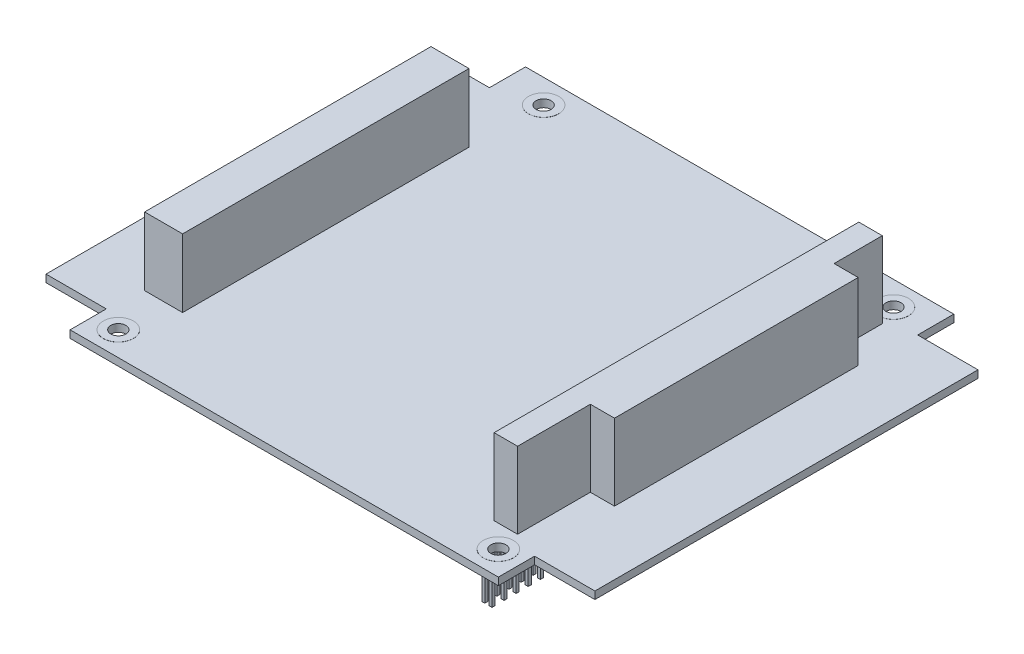
from build123d import *

# Parameters (mm, degrees)
BASE_EXTRUDE_DEPTH         = 1.57
SKETCH2_R                  = 1.59
MOUNTING_HOLES_DEPTH       = 76.101891787
TOP_START                  = 0.02
SKETCH3_R                  = 3.175
SKETCH3_R_2                = 1.59
TOP_PADS_DEPTH             = 0.02
SKETCH4_R                  = 3.175
SKETCH4_R_2                = 1.59
BOTT_PADS_DEPTH            = 0.02
ISA_CNCT_DEPTH             = 16.05
SKETCH6_W                  = 8
SKETCH6_H                  = 60.3
PCI_CNCT_DEPTH             = 14.35
SKETCH7_W                  = 11.3
SKETCH7_H                  = 63.35
SKETCH7_W_2                = 8.51
SKETCH7_H_2                = 60.96
PCI_CNCT_SHROUD_DEPTH      = 11.18
SKETCH8_W                  = 0.64
SKETCH8_H                  = 0.64
BOT_ISA_DEPTH              = 10.67
LPATTERN1_COUNT            = 32
LPATTERN1_PITCH            = 2.54
SKETCH9_W                  = 0.64
SKETCH9_H                  = 0.64
BOSS_EXTRUDE7_DEPTH        = 10.67
LPATTERN2_COUNT            = 20
LPATTERN2_PITCH            = 2.54
SKETCH10_W                 = 0.5
SKETCH10_H                 = 0.5
PCI_BASE_DEPTH             = 10.41
LPATTERN3_COUNT            = 30
LPATTERN3_PITCH            = 2
LPATTERN4_COUNT            = 4
LPATTERN4_PITCH            = 2
LPATTERN4_COPY_1_SKETCH_W  = 0.5
LPATTERN4_COPY_1_SKETCH_H  = 0.5
LPATTERN4_COPY_1_DEPTH     = 10.41
LPATTERN4_COPY_2_SKETCH_W  = 0.5
LPATTERN4_COPY_2_SKETCH_H  = 0.5
LPATTERN4_COPY_2_DEPTH     = 10.41
LPATTERN4_COPY_3_SKETCH_W  = 0.5
LPATTERN4_COPY_3_SKETCH_H  = 0.5
LPATTERN4_COPY_3_DEPTH     = 10.41
LPATTERN4_COPY_4_SKETCH_W  = 0.5
LPATTERN4_COPY_4_SKETCH_H  = 0.5
LPATTERN4_COPY_4_DEPTH     = 10.41
LPATTERN4_COPY_5_SKETCH_W  = 0.5
LPATTERN4_COPY_5_SKETCH_H  = 0.5
LPATTERN4_COPY_5_DEPTH     = 10.41
LPATTERN4_COPY_6_SKETCH_W  = 0.5
LPATTERN4_COPY_6_SKETCH_H  = 0.5
LPATTERN4_COPY_6_DEPTH     = 10.41
LPATTERN4_COPY_7_SKETCH_W  = 0.5
LPATTERN4_COPY_7_SKETCH_H  = 0.5
LPATTERN4_COPY_7_DEPTH     = 10.41
LPATTERN4_COPY_8_SKETCH_W  = 0.5
LPATTERN4_COPY_8_SKETCH_H  = 0.5
LPATTERN4_COPY_8_DEPTH     = 10.41
LPATTERN4_COPY_9_SKETCH_W  = 0.5
LPATTERN4_COPY_9_SKETCH_H  = 0.5
LPATTERN4_COPY_9_DEPTH     = 10.41
LPATTERN4_COPY_10_SKETCH_W = 0.5
LPATTERN4_COPY_10_SKETCH_H = 0.5
LPATTERN4_COPY_10_DEPTH    = 10.41
LPATTERN4_COPY_11_SKETCH_W = 0.5
LPATTERN4_COPY_11_SKETCH_H = 0.5
LPATTERN4_COPY_11_DEPTH    = 10.41
LPATTERN4_COPY_12_SKETCH_W = 0.5
LPATTERN4_COPY_12_SKETCH_H = 0.5
LPATTERN4_COPY_12_DEPTH    = 10.41
LPATTERN4_COPY_13_SKETCH_W = 0.5
LPATTERN4_COPY_13_SKETCH_H = 0.5
LPATTERN4_COPY_13_DEPTH    = 10.41
LPATTERN4_COPY_14_SKETCH_W = 0.5
LPATTERN4_COPY_14_SKETCH_H = 0.5
LPATTERN4_COPY_14_DEPTH    = 10.41
LPATTERN4_COPY_15_SKETCH_W = 0.5
LPATTERN4_COPY_15_SKETCH_H = 0.5
LPATTERN4_COPY_15_DEPTH    = 10.41
LPATTERN4_COPY_16_SKETCH_W = 0.5
LPATTERN4_COPY_16_SKETCH_H = 0.5
LPATTERN4_COPY_16_DEPTH    = 10.41
LPATTERN4_COPY_17_SKETCH_W = 0.5
LPATTERN4_COPY_17_SKETCH_H = 0.5
LPATTERN4_COPY_17_DEPTH    = 10.41
LPATTERN4_COPY_18_SKETCH_W = 0.5
LPATTERN4_COPY_18_SKETCH_H = 0.5
LPATTERN4_COPY_18_DEPTH    = 10.41
LPATTERN4_COPY_19_SKETCH_W = 0.5
LPATTERN4_COPY_19_SKETCH_H = 0.5
LPATTERN4_COPY_19_DEPTH    = 10.41
LPATTERN4_COPY_20_SKETCH_W = 0.5
LPATTERN4_COPY_20_SKETCH_H = 0.5
LPATTERN4_COPY_20_DEPTH    = 10.41
LPATTERN4_COPY_21_SKETCH_W = 0.5
LPATTERN4_COPY_21_SKETCH_H = 0.5
LPATTERN4_COPY_21_DEPTH    = 10.41
LPATTERN4_COPY_22_SKETCH_W = 0.5
LPATTERN4_COPY_22_SKETCH_H = 0.5
LPATTERN4_COPY_22_DEPTH    = 10.41
LPATTERN4_COPY_23_SKETCH_W = 0.5
LPATTERN4_COPY_23_SKETCH_H = 0.5
LPATTERN4_COPY_23_DEPTH    = 10.41
LPATTERN4_COPY_24_SKETCH_W = 0.5
LPATTERN4_COPY_24_SKETCH_H = 0.5
LPATTERN4_COPY_24_DEPTH    = 10.41
LPATTERN4_COPY_25_SKETCH_W = 0.5
LPATTERN4_COPY_25_SKETCH_H = 0.5
LPATTERN4_COPY_25_DEPTH    = 10.41
LPATTERN4_COPY_26_SKETCH_W = 0.5
LPATTERN4_COPY_26_SKETCH_H = 0.5
LPATTERN4_COPY_26_DEPTH    = 10.41
LPATTERN4_COPY_27_SKETCH_W = 0.5
LPATTERN4_COPY_27_SKETCH_H = 0.5
LPATTERN4_COPY_27_DEPTH    = 10.41
LPATTERN4_COPY_28_SKETCH_W = 0.5
LPATTERN4_COPY_28_SKETCH_H = 0.5
LPATTERN4_COPY_28_DEPTH    = 10.41
LPATTERN4_COPY_29_SKETCH_W = 0.5
LPATTERN4_COPY_29_SKETCH_H = 0.5
LPATTERN4_COPY_29_DEPTH    = 10.41
LPATTERN4_COPY_30_SKETCH_W = 0.5
LPATTERN4_COPY_30_SKETCH_H = 0.5
LPATTERN4_COPY_30_DEPTH    = 10.41
LPATTERN4_COPY_31_SKETCH_W = 0.5
LPATTERN4_COPY_31_SKETCH_H = 0.5
LPATTERN4_COPY_31_DEPTH    = 10.41
LPATTERN4_COPY_32_SKETCH_W = 0.5
LPATTERN4_COPY_32_SKETCH_H = 0.5
LPATTERN4_COPY_32_DEPTH    = 10.41
LPATTERN4_COPY_33_SKETCH_W = 0.5
LPATTERN4_COPY_33_SKETCH_H = 0.5
LPATTERN4_COPY_33_DEPTH    = 10.41
LPATTERN4_COPY_34_SKETCH_W = 0.5
LPATTERN4_COPY_34_SKETCH_H = 0.5
LPATTERN4_COPY_34_DEPTH    = 10.41
LPATTERN4_COPY_35_SKETCH_W = 0.5
LPATTERN4_COPY_35_SKETCH_H = 0.5
LPATTERN4_COPY_35_DEPTH    = 10.41
LPATTERN4_COPY_36_SKETCH_W = 0.5
LPATTERN4_COPY_36_SKETCH_H = 0.5
LPATTERN4_COPY_36_DEPTH    = 10.41
LPATTERN4_COPY_37_SKETCH_W = 0.5
LPATTERN4_COPY_37_SKETCH_H = 0.5
LPATTERN4_COPY_37_DEPTH    = 10.41
LPATTERN4_COPY_38_SKETCH_W = 0.5
LPATTERN4_COPY_38_SKETCH_H = 0.5
LPATTERN4_COPY_38_DEPTH    = 10.41
LPATTERN4_COPY_39_SKETCH_W = 0.5
LPATTERN4_COPY_39_SKETCH_H = 0.5
LPATTERN4_COPY_39_DEPTH    = 10.41
LPATTERN4_COPY_40_SKETCH_W = 0.5
LPATTERN4_COPY_40_SKETCH_H = 0.5
LPATTERN4_COPY_40_DEPTH    = 10.41
LPATTERN4_COPY_41_SKETCH_W = 0.5
LPATTERN4_COPY_41_SKETCH_H = 0.5
LPATTERN4_COPY_41_DEPTH    = 10.41
LPATTERN4_COPY_42_SKETCH_W = 0.5
LPATTERN4_COPY_42_SKETCH_H = 0.5
LPATTERN4_COPY_42_DEPTH    = 10.41
LPATTERN4_COPY_43_SKETCH_W = 0.5
LPATTERN4_COPY_43_SKETCH_H = 0.5
LPATTERN4_COPY_43_DEPTH    = 10.41
LPATTERN4_COPY_44_SKETCH_W = 0.5
LPATTERN4_COPY_44_SKETCH_H = 0.5
LPATTERN4_COPY_44_DEPTH    = 10.41
LPATTERN4_COPY_45_SKETCH_W = 0.5
LPATTERN4_COPY_45_SKETCH_H = 0.5
LPATTERN4_COPY_45_DEPTH    = 10.41
LPATTERN4_COPY_46_SKETCH_W = 0.5
LPATTERN4_COPY_46_SKETCH_H = 0.5
LPATTERN4_COPY_46_DEPTH    = 10.41
LPATTERN4_COPY_47_SKETCH_W = 0.5
LPATTERN4_COPY_47_SKETCH_H = 0.5
LPATTERN4_COPY_47_DEPTH    = 10.41
LPATTERN4_COPY_48_SKETCH_W = 0.5
LPATTERN4_COPY_48_SKETCH_H = 0.5
LPATTERN4_COPY_48_DEPTH    = 10.41
LPATTERN4_COPY_49_SKETCH_W = 0.5
LPATTERN4_COPY_49_SKETCH_H = 0.5
LPATTERN4_COPY_49_DEPTH    = 10.41
LPATTERN4_COPY_50_SKETCH_W = 0.5
LPATTERN4_COPY_50_SKETCH_H = 0.5
LPATTERN4_COPY_50_DEPTH    = 10.41
LPATTERN4_COPY_51_SKETCH_W = 0.5
LPATTERN4_COPY_51_SKETCH_H = 0.5
LPATTERN4_COPY_51_DEPTH    = 10.41
LPATTERN4_COPY_52_SKETCH_W = 0.5
LPATTERN4_COPY_52_SKETCH_H = 0.5
LPATTERN4_COPY_52_DEPTH    = 10.41
LPATTERN4_COPY_53_SKETCH_W = 0.5
LPATTERN4_COPY_53_SKETCH_H = 0.5
LPATTERN4_COPY_53_DEPTH    = 10.41
LPATTERN4_COPY_54_SKETCH_W = 0.5
LPATTERN4_COPY_54_SKETCH_H = 0.5
LPATTERN4_COPY_54_DEPTH    = 10.41
LPATTERN4_COPY_55_SKETCH_W = 0.5
LPATTERN4_COPY_55_SKETCH_H = 0.5
LPATTERN4_COPY_55_DEPTH    = 10.41
LPATTERN4_COPY_56_SKETCH_W = 0.5
LPATTERN4_COPY_56_SKETCH_H = 0.5
LPATTERN4_COPY_56_DEPTH    = 10.41
LPATTERN4_COPY_57_SKETCH_W = 0.5
LPATTERN4_COPY_57_SKETCH_H = 0.5
LPATTERN4_COPY_57_DEPTH    = 10.41
LPATTERN4_COPY_58_SKETCH_W = 0.5
LPATTERN4_COPY_58_SKETCH_H = 0.5
LPATTERN4_COPY_58_DEPTH    = 10.41
LPATTERN4_COPY_59_SKETCH_W = 0.5
LPATTERN4_COPY_59_SKETCH_H = 0.5
LPATTERN4_COPY_59_DEPTH    = 10.41
LPATTERN4_COPY_60_SKETCH_W = 0.5
LPATTERN4_COPY_60_SKETCH_H = 0.5
LPATTERN4_COPY_60_DEPTH    = 10.41
LPATTERN4_COPY_61_SKETCH_W = 0.5
LPATTERN4_COPY_61_SKETCH_H = 0.5
LPATTERN4_COPY_61_DEPTH    = 10.41
LPATTERN4_COPY_62_SKETCH_W = 0.5
LPATTERN4_COPY_62_SKETCH_H = 0.5
LPATTERN4_COPY_62_DEPTH    = 10.41
LPATTERN4_COPY_63_SKETCH_W = 0.5
LPATTERN4_COPY_63_SKETCH_H = 0.5
LPATTERN4_COPY_63_DEPTH    = 10.41
LPATTERN4_COPY_64_SKETCH_W = 0.5
LPATTERN4_COPY_64_SKETCH_H = 0.5
LPATTERN4_COPY_64_DEPTH    = 10.41
LPATTERN4_COPY_65_SKETCH_W = 0.5
LPATTERN4_COPY_65_SKETCH_H = 0.5
LPATTERN4_COPY_65_DEPTH    = 10.41
LPATTERN4_COPY_66_SKETCH_W = 0.5
LPATTERN4_COPY_66_SKETCH_H = 0.5
LPATTERN4_COPY_66_DEPTH    = 10.41
LPATTERN4_COPY_67_SKETCH_W = 0.5
LPATTERN4_COPY_67_SKETCH_H = 0.5
LPATTERN4_COPY_67_DEPTH    = 10.41
LPATTERN4_COPY_68_SKETCH_W = 0.5
LPATTERN4_COPY_68_SKETCH_H = 0.5
LPATTERN4_COPY_68_DEPTH    = 10.41
LPATTERN4_COPY_69_SKETCH_W = 0.5
LPATTERN4_COPY_69_SKETCH_H = 0.5
LPATTERN4_COPY_69_DEPTH    = 10.41
LPATTERN4_COPY_70_SKETCH_W = 0.5
LPATTERN4_COPY_70_SKETCH_H = 0.5
LPATTERN4_COPY_70_DEPTH    = 10.41
LPATTERN4_COPY_71_SKETCH_W = 0.5
LPATTERN4_COPY_71_SKETCH_H = 0.5
LPATTERN4_COPY_71_DEPTH    = 10.41
LPATTERN4_COPY_72_SKETCH_W = 0.5
LPATTERN4_COPY_72_SKETCH_H = 0.5
LPATTERN4_COPY_72_DEPTH    = 10.41
LPATTERN4_COPY_73_SKETCH_W = 0.5
LPATTERN4_COPY_73_SKETCH_H = 0.5
LPATTERN4_COPY_73_DEPTH    = 10.41
LPATTERN4_COPY_74_SKETCH_W = 0.5
LPATTERN4_COPY_74_SKETCH_H = 0.5
LPATTERN4_COPY_74_DEPTH    = 10.41
LPATTERN4_COPY_75_SKETCH_W = 0.5
LPATTERN4_COPY_75_SKETCH_H = 0.5
LPATTERN4_COPY_75_DEPTH    = 10.41
LPATTERN4_COPY_76_SKETCH_W = 0.5
LPATTERN4_COPY_76_SKETCH_H = 0.5
LPATTERN4_COPY_76_DEPTH    = 10.41
LPATTERN4_COPY_77_SKETCH_W = 0.5
LPATTERN4_COPY_77_SKETCH_H = 0.5
LPATTERN4_COPY_77_DEPTH    = 10.41
LPATTERN4_COPY_78_SKETCH_W = 0.5
LPATTERN4_COPY_78_SKETCH_H = 0.5
LPATTERN4_COPY_78_DEPTH    = 10.41
LPATTERN4_COPY_79_SKETCH_W = 0.5
LPATTERN4_COPY_79_SKETCH_H = 0.5
LPATTERN4_COPY_79_DEPTH    = 10.41
LPATTERN4_COPY_80_SKETCH_W = 0.5
LPATTERN4_COPY_80_SKETCH_H = 0.5
LPATTERN4_COPY_80_DEPTH    = 10.41
LPATTERN4_COPY_81_SKETCH_W = 0.5
LPATTERN4_COPY_81_SKETCH_H = 0.5
LPATTERN4_COPY_81_DEPTH    = 10.41
LPATTERN4_COPY_82_SKETCH_W = 0.5
LPATTERN4_COPY_82_SKETCH_H = 0.5
LPATTERN4_COPY_82_DEPTH    = 10.41
LPATTERN4_COPY_83_SKETCH_W = 0.5
LPATTERN4_COPY_83_SKETCH_H = 0.5
LPATTERN4_COPY_83_DEPTH    = 10.41
LPATTERN4_COPY_84_SKETCH_W = 0.5
LPATTERN4_COPY_84_SKETCH_H = 0.5
LPATTERN4_COPY_84_DEPTH    = 10.41
LPATTERN4_COPY_85_SKETCH_W = 0.5
LPATTERN4_COPY_85_SKETCH_H = 0.5
LPATTERN4_COPY_85_DEPTH    = 10.41
LPATTERN4_COPY_86_SKETCH_W = 0.5
LPATTERN4_COPY_86_SKETCH_H = 0.5
LPATTERN4_COPY_86_DEPTH    = 10.41
LPATTERN4_COPY_87_SKETCH_W = 0.5
LPATTERN4_COPY_87_SKETCH_H = 0.5
LPATTERN4_COPY_87_DEPTH    = 10.41


with BuildPart() as part:
    # Sketch1 → Base-Extrude (new body)
    with BuildSketch(Plane(origin=(0, 0, 0), x_dir=(1, 0, 0), z_dir=(0, 1, 0))):
        Polygon((-45.085, 47.945), (45.085, 47.945), (45.085, 40.343374485), (57.785, 40.343374485), (57.785, -40.318146652), (45.085, -40.318146652), (45.085, -47.945), (-45.085, -47.945), (-45.085, -40.318146652), (-57.785, -40.318146652), (-57.785, 40.343374485), (-45.085, 40.343374485), align=None)
    extrude(amount=BASE_EXTRUDE_DEPTH)

    # Sketch2 → Mounting Holes (cut, through all)
    with BuildSketch(Plane(origin=(0, 1.57, 0), x_dir=(-1, 0, 0), z_dir=(0, 1, 0))):
        with Locations(Location((36.195, -42.865, 0), (0, 0, 90))):
            Circle(SKETCH2_R)
        with Locations(Location((40.005, 42.865, 0), (0, 0, 90))):
            Circle(SKETCH2_R)
        with Locations(Location((-40.005, 42.865, 0), (0, 0, 90))):
            Circle(SKETCH2_R)
        with Locations(Location((-37.465, -42.865, 0), (0, 0, 90))):
            Circle(SKETCH2_R)
    extrude(amount=-MOUNTING_HOLES_DEPTH, mode=Mode.SUBTRACT)

    # Sketch3 → Top Pads (add)
    # profile 1 of 4: a face of its own
    with BuildSketch(Plane(origin=(0, 1.57, 0), x_dir=(-1, 0, 0), z_dir=(0, 1, 0)).offset(TOP_START)):
        with Locations(Location((36.195, -42.865, 0), (0, 0, 270))):
            Circle(SKETCH3_R)
        with Locations(Location((36.195, -42.865, 0), (0, 0, 90))):
            Circle(SKETCH3_R_2, mode=Mode.SUBTRACT)
    # profile 2 of 4: a face of its own
    with BuildSketch(Plane(origin=(0, 1.57, 0), x_dir=(-1, 0, 0), z_dir=(0, 1, 0)).offset(TOP_START)):
        with Locations(Location((-37.465, -42.865, 0), (0, 0, 270))):
            Circle(SKETCH3_R)
        with Locations(Location((-37.465, -42.865, 0), (0, 0, 90))):
            Circle(SKETCH3_R_2, mode=Mode.SUBTRACT)
    # profile 3 of 4: a face of its own
    with BuildSketch(Plane(origin=(0, 1.57, 0), x_dir=(-1, 0, 0), z_dir=(0, 1, 0)).offset(TOP_START)):
        with Locations(Location((-40.005, 42.865, 0), (0, 0, 270))):
            Circle(SKETCH3_R)
        with Locations(Location((-40.005, 42.865, 0), (0, 0, 90))):
            Circle(SKETCH3_R_2, mode=Mode.SUBTRACT)
    # profile 4 of 4: a face of its own
    with BuildSketch(Plane(origin=(0, 1.57, 0), x_dir=(-1, 0, 0), z_dir=(0, 1, 0)).offset(TOP_START)):
        with Locations(Location((40.005, 42.865, 0), (0, 0, 270))):
            Circle(SKETCH3_R)
        with Locations(Location((40.005, 42.865, 0), (0, 0, 90))):
            Circle(SKETCH3_R_2, mode=Mode.SUBTRACT)
    extrude(amount=-TOP_PADS_DEPTH)

    # Sketch4 → Bott Pads (add)
    # profile 1 of 4: a face of its own
    with BuildSketch(Plane.XZ):
        with Locations(Location((-36.195, -42.865, 0), (0, 0, 270))):
            Circle(SKETCH4_R)
        with Locations(Location((-36.195, -42.865, 0), (0, 0, 90))):
            Circle(SKETCH4_R_2, mode=Mode.SUBTRACT)
    # profile 2 of 4: a face of its own
    with BuildSketch(Plane.XZ):
        with Locations(Location((37.465, -42.865, 0), (0, 0, 270))):
            Circle(SKETCH4_R)
        with Locations(Location((37.465, -42.865, 0), (0, 0, 90))):
            Circle(SKETCH4_R_2, mode=Mode.SUBTRACT)
    # profile 3 of 4: a face of its own
    with BuildSketch(Plane.XZ):
        with Locations(Location((40.005, 42.865, 0), (0, 0, 270))):
            Circle(SKETCH4_R)
        with Locations(Location((40.005, 42.865, 0), (0, 0, 90))):
            Circle(SKETCH4_R_2, mode=Mode.SUBTRACT)
    # profile 4 of 4: a face of its own
    with BuildSketch(Plane.XZ):
        with Locations(Location((-40.005, 42.865, 0), (0, 0, 270))):
            Circle(SKETCH4_R)
        with Locations(Location((-40.005, 42.865, 0), (0, 0, 90))):
            Circle(SKETCH4_R_2, mode=Mode.SUBTRACT)
    extrude(amount=BOTT_PADS_DEPTH)

    # Sketch5 → ISA Cnct (add)
    with BuildSketch(Plane(origin=(0, 1.57, 0), x_dir=(-1, 0, 0), z_dir=(0, 1, 0))):
        Polygon((-39.305, 22.795), (-39.305, 38.115), (-34.355, 38.115), (-34.355, -38.675), (-39.305, -38.675), (-39.305, -28.515), (-44.385, -28.515), (-44.385, 22.795), align=None)
    extrude(amount=ISA_CNCT_DEPTH)

    # Sketch6 → PCI Cnct (add)
    with BuildSketch(Plane(origin=(0, 1.57, 0), x_dir=(-1, 0, 0), z_dir=(0, 1, 0))):
        with Locations((40.385, 2.805)):
            Rectangle(SKETCH6_W, SKETCH6_H)
    extrude(amount=PCI_CNCT_DEPTH)

    # Sketch7 → PCI Cnct Shroud (add)
    with BuildSketch(Plane.XZ):
        with Locations((-40.385, 2.805)):
            Rectangle(SKETCH7_W, SKETCH7_H)
        with Locations((-40.385, 2.805)):
            Rectangle(SKETCH7_W_2, SKETCH7_H_2, mode=Mode.SUBTRACT)
    extrude(amount=PCI_CNCT_SHROUD_DEPTH)

    # Sketch8 → Bot ISA (add)
    with BuildSketch(Plane.XZ):
        with Locations((35.875, -37.155)):
            Rectangle(SKETCH8_W, SKETCH8_H)
        with Locations((37.395, -37.155)):
            Rectangle(SKETCH8_W, SKETCH8_H)
    bot_isa = extrude(amount=BOT_ISA_DEPTH)

    # LPattern1: Bot ISA ×32
    with Locations(*[(0, 0, i * LPATTERN1_PITCH) for i in range(1, LPATTERN1_COUNT)]):
        add(bot_isa)

    # Sketch9 → Boss-Extrude7 (add)
    with BuildSketch(Plane.XZ):
        with Locations((40.325, -26.995)):
            Rectangle(SKETCH9_W, SKETCH9_H)
        with Locations((42.865, -26.995)):
            Rectangle(SKETCH9_W, SKETCH9_H)
    boss_extrude7 = extrude(amount=BOSS_EXTRUDE7_DEPTH)

    # LPattern2: Boss-Extrude7 ×20
    with Locations(*[(0, 0, i * LPATTERN2_PITCH) for i in range(1, LPATTERN2_COUNT)]):
        add(boss_extrude7)

    # Sketch10 → PCI Base (add)
    with BuildSketch(Plane.XZ):
        with Locations((-43.395, -25.675)):
            Rectangle(SKETCH10_W, SKETCH10_H)
    pci_base = extrude(amount=PCI_BASE_DEPTH)

    # LPattern3: PCI Base ×30
    with Locations(*[(0, 0, i * LPATTERN3_PITCH) for i in range(1, LPATTERN3_COUNT)]):
        add(pci_base)

    # LPattern4: PCI Base ×4
    with Locations(*[(i * LPATTERN4_PITCH, 0, 0) for i in range(1, LPATTERN4_COUNT)]):
        add(pci_base)

    # LPattern4 copy 1 sketch → LPattern4 copy 1 (add)
    with BuildSketch(Plane(origin=(2, 0, 2), x_dir=(1, 0, 0), z_dir=(0, -1, 0))):
        with Locations((-43.395, -25.675)):
            Rectangle(LPATTERN4_COPY_1_SKETCH_W, LPATTERN4_COPY_1_SKETCH_H)
    extrude(amount=LPATTERN4_COPY_1_DEPTH)

    # LPattern4 copy 2 sketch → LPattern4 copy 2 (add)
    with BuildSketch(Plane(origin=(4, 0, 2), x_dir=(1, 0, 0), z_dir=(0, -1, 0))):
        with Locations((-43.395, -25.675)):
            Rectangle(LPATTERN4_COPY_2_SKETCH_W, LPATTERN4_COPY_2_SKETCH_H)
    extrude(amount=LPATTERN4_COPY_2_DEPTH)

    # LPattern4 copy 3 sketch → LPattern4 copy 3 (add)
    with BuildSketch(Plane(origin=(6, 0, 2), x_dir=(1, 0, 0), z_dir=(0, -1, 0))):
        with Locations((-43.395, -25.675)):
            Rectangle(LPATTERN4_COPY_3_SKETCH_W, LPATTERN4_COPY_3_SKETCH_H)
    extrude(amount=LPATTERN4_COPY_3_DEPTH)

    # LPattern4 copy 4 sketch → LPattern4 copy 4 (add)
    with BuildSketch(Plane(origin=(2, 0, 4), x_dir=(1, 0, 0), z_dir=(0, -1, 0))):
        with Locations((-43.395, -25.675)):
            Rectangle(LPATTERN4_COPY_4_SKETCH_W, LPATTERN4_COPY_4_SKETCH_H)
    extrude(amount=LPATTERN4_COPY_4_DEPTH)

    # LPattern4 copy 5 sketch → LPattern4 copy 5 (add)
    with BuildSketch(Plane(origin=(4, 0, 4), x_dir=(1, 0, 0), z_dir=(0, -1, 0))):
        with Locations((-43.395, -25.675)):
            Rectangle(LPATTERN4_COPY_5_SKETCH_W, LPATTERN4_COPY_5_SKETCH_H)
    extrude(amount=LPATTERN4_COPY_5_DEPTH)

    # LPattern4 copy 6 sketch → LPattern4 copy 6 (add)
    with BuildSketch(Plane(origin=(6, 0, 4), x_dir=(1, 0, 0), z_dir=(0, -1, 0))):
        with Locations((-43.395, -25.675)):
            Rectangle(LPATTERN4_COPY_6_SKETCH_W, LPATTERN4_COPY_6_SKETCH_H)
    extrude(amount=LPATTERN4_COPY_6_DEPTH)

    # LPattern4 copy 7 sketch → LPattern4 copy 7 (add)
    with BuildSketch(Plane(origin=(2, 0, 6), x_dir=(1, 0, 0), z_dir=(0, -1, 0))):
        with Locations((-43.395, -25.675)):
            Rectangle(LPATTERN4_COPY_7_SKETCH_W, LPATTERN4_COPY_7_SKETCH_H)
    extrude(amount=LPATTERN4_COPY_7_DEPTH)

    # LPattern4 copy 8 sketch → LPattern4 copy 8 (add)
    with BuildSketch(Plane(origin=(4, 0, 6), x_dir=(1, 0, 0), z_dir=(0, -1, 0))):
        with Locations((-43.395, -25.675)):
            Rectangle(LPATTERN4_COPY_8_SKETCH_W, LPATTERN4_COPY_8_SKETCH_H)
    extrude(amount=LPATTERN4_COPY_8_DEPTH)

    # LPattern4 copy 9 sketch → LPattern4 copy 9 (add)
    with BuildSketch(Plane(origin=(6, 0, 6), x_dir=(1, 0, 0), z_dir=(0, -1, 0))):
        with Locations((-43.395, -25.675)):
            Rectangle(LPATTERN4_COPY_9_SKETCH_W, LPATTERN4_COPY_9_SKETCH_H)
    extrude(amount=LPATTERN4_COPY_9_DEPTH)

    # LPattern4 copy 10 sketch → LPattern4 copy 10 (add)
    with BuildSketch(Plane(origin=(2, 0, 8), x_dir=(1, 0, 0), z_dir=(0, -1, 0))):
        with Locations((-43.395, -25.675)):
            Rectangle(LPATTERN4_COPY_10_SKETCH_W, LPATTERN4_COPY_10_SKETCH_H)
    extrude(amount=LPATTERN4_COPY_10_DEPTH)

    # LPattern4 copy 11 sketch → LPattern4 copy 11 (add)
    with BuildSketch(Plane(origin=(4, 0, 8), x_dir=(1, 0, 0), z_dir=(0, -1, 0))):
        with Locations((-43.395, -25.675)):
            Rectangle(LPATTERN4_COPY_11_SKETCH_W, LPATTERN4_COPY_11_SKETCH_H)
    extrude(amount=LPATTERN4_COPY_11_DEPTH)

    # LPattern4 copy 12 sketch → LPattern4 copy 12 (add)
    with BuildSketch(Plane(origin=(6, 0, 8), x_dir=(1, 0, 0), z_dir=(0, -1, 0))):
        with Locations((-43.395, -25.675)):
            Rectangle(LPATTERN4_COPY_12_SKETCH_W, LPATTERN4_COPY_12_SKETCH_H)
    extrude(amount=LPATTERN4_COPY_12_DEPTH)

    # LPattern4 copy 13 sketch → LPattern4 copy 13 (add)
    with BuildSketch(Plane(origin=(2, 0, 10), x_dir=(1, 0, 0), z_dir=(0, -1, 0))):
        with Locations((-43.395, -25.675)):
            Rectangle(LPATTERN4_COPY_13_SKETCH_W, LPATTERN4_COPY_13_SKETCH_H)
    extrude(amount=LPATTERN4_COPY_13_DEPTH)

    # LPattern4 copy 14 sketch → LPattern4 copy 14 (add)
    with BuildSketch(Plane(origin=(4, 0, 10), x_dir=(1, 0, 0), z_dir=(0, -1, 0))):
        with Locations((-43.395, -25.675)):
            Rectangle(LPATTERN4_COPY_14_SKETCH_W, LPATTERN4_COPY_14_SKETCH_H)
    extrude(amount=LPATTERN4_COPY_14_DEPTH)

    # LPattern4 copy 15 sketch → LPattern4 copy 15 (add)
    with BuildSketch(Plane(origin=(6, 0, 10), x_dir=(1, 0, 0), z_dir=(0, -1, 0))):
        with Locations((-43.395, -25.675)):
            Rectangle(LPATTERN4_COPY_15_SKETCH_W, LPATTERN4_COPY_15_SKETCH_H)
    extrude(amount=LPATTERN4_COPY_15_DEPTH)

    # LPattern4 copy 16 sketch → LPattern4 copy 16 (add)
    with BuildSketch(Plane(origin=(2, 0, 12), x_dir=(1, 0, 0), z_dir=(0, -1, 0))):
        with Locations((-43.395, -25.675)):
            Rectangle(LPATTERN4_COPY_16_SKETCH_W, LPATTERN4_COPY_16_SKETCH_H)
    extrude(amount=LPATTERN4_COPY_16_DEPTH)

    # LPattern4 copy 17 sketch → LPattern4 copy 17 (add)
    with BuildSketch(Plane(origin=(4, 0, 12), x_dir=(1, 0, 0), z_dir=(0, -1, 0))):
        with Locations((-43.395, -25.675)):
            Rectangle(LPATTERN4_COPY_17_SKETCH_W, LPATTERN4_COPY_17_SKETCH_H)
    extrude(amount=LPATTERN4_COPY_17_DEPTH)

    # LPattern4 copy 18 sketch → LPattern4 copy 18 (add)
    with BuildSketch(Plane(origin=(6, 0, 12), x_dir=(1, 0, 0), z_dir=(0, -1, 0))):
        with Locations((-43.395, -25.675)):
            Rectangle(LPATTERN4_COPY_18_SKETCH_W, LPATTERN4_COPY_18_SKETCH_H)
    extrude(amount=LPATTERN4_COPY_18_DEPTH)

    # LPattern4 copy 19 sketch → LPattern4 copy 19 (add)
    with BuildSketch(Plane(origin=(2, 0, 14), x_dir=(1, 0, 0), z_dir=(0, -1, 0))):
        with Locations((-43.395, -25.675)):
            Rectangle(LPATTERN4_COPY_19_SKETCH_W, LPATTERN4_COPY_19_SKETCH_H)
    extrude(amount=LPATTERN4_COPY_19_DEPTH)

    # LPattern4 copy 20 sketch → LPattern4 copy 20 (add)
    with BuildSketch(Plane(origin=(4, 0, 14), x_dir=(1, 0, 0), z_dir=(0, -1, 0))):
        with Locations((-43.395, -25.675)):
            Rectangle(LPATTERN4_COPY_20_SKETCH_W, LPATTERN4_COPY_20_SKETCH_H)
    extrude(amount=LPATTERN4_COPY_20_DEPTH)

    # LPattern4 copy 21 sketch → LPattern4 copy 21 (add)
    with BuildSketch(Plane(origin=(6, 0, 14), x_dir=(1, 0, 0), z_dir=(0, -1, 0))):
        with Locations((-43.395, -25.675)):
            Rectangle(LPATTERN4_COPY_21_SKETCH_W, LPATTERN4_COPY_21_SKETCH_H)
    extrude(amount=LPATTERN4_COPY_21_DEPTH)

    # LPattern4 copy 22 sketch → LPattern4 copy 22 (add)
    with BuildSketch(Plane(origin=(2, 0, 16), x_dir=(1, 0, 0), z_dir=(0, -1, 0))):
        with Locations((-43.395, -25.675)):
            Rectangle(LPATTERN4_COPY_22_SKETCH_W, LPATTERN4_COPY_22_SKETCH_H)
    extrude(amount=LPATTERN4_COPY_22_DEPTH)

    # LPattern4 copy 23 sketch → LPattern4 copy 23 (add)
    with BuildSketch(Plane(origin=(4, 0, 16), x_dir=(1, 0, 0), z_dir=(0, -1, 0))):
        with Locations((-43.395, -25.675)):
            Rectangle(LPATTERN4_COPY_23_SKETCH_W, LPATTERN4_COPY_23_SKETCH_H)
    extrude(amount=LPATTERN4_COPY_23_DEPTH)

    # LPattern4 copy 24 sketch → LPattern4 copy 24 (add)
    with BuildSketch(Plane(origin=(6, 0, 16), x_dir=(1, 0, 0), z_dir=(0, -1, 0))):
        with Locations((-43.395, -25.675)):
            Rectangle(LPATTERN4_COPY_24_SKETCH_W, LPATTERN4_COPY_24_SKETCH_H)
    extrude(amount=LPATTERN4_COPY_24_DEPTH)

    # LPattern4 copy 25 sketch → LPattern4 copy 25 (add)
    with BuildSketch(Plane(origin=(2, 0, 18), x_dir=(1, 0, 0), z_dir=(0, -1, 0))):
        with Locations((-43.395, -25.675)):
            Rectangle(LPATTERN4_COPY_25_SKETCH_W, LPATTERN4_COPY_25_SKETCH_H)
    extrude(amount=LPATTERN4_COPY_25_DEPTH)

    # LPattern4 copy 26 sketch → LPattern4 copy 26 (add)
    with BuildSketch(Plane(origin=(4, 0, 18), x_dir=(1, 0, 0), z_dir=(0, -1, 0))):
        with Locations((-43.395, -25.675)):
            Rectangle(LPATTERN4_COPY_26_SKETCH_W, LPATTERN4_COPY_26_SKETCH_H)
    extrude(amount=LPATTERN4_COPY_26_DEPTH)

    # LPattern4 copy 27 sketch → LPattern4 copy 27 (add)
    with BuildSketch(Plane(origin=(6, 0, 18), x_dir=(1, 0, 0), z_dir=(0, -1, 0))):
        with Locations((-43.395, -25.675)):
            Rectangle(LPATTERN4_COPY_27_SKETCH_W, LPATTERN4_COPY_27_SKETCH_H)
    extrude(amount=LPATTERN4_COPY_27_DEPTH)

    # LPattern4 copy 28 sketch → LPattern4 copy 28 (add)
    with BuildSketch(Plane(origin=(2, 0, 20), x_dir=(1, 0, 0), z_dir=(0, -1, 0))):
        with Locations((-43.395, -25.675)):
            Rectangle(LPATTERN4_COPY_28_SKETCH_W, LPATTERN4_COPY_28_SKETCH_H)
    extrude(amount=LPATTERN4_COPY_28_DEPTH)

    # LPattern4 copy 29 sketch → LPattern4 copy 29 (add)
    with BuildSketch(Plane(origin=(4, 0, 20), x_dir=(1, 0, 0), z_dir=(0, -1, 0))):
        with Locations((-43.395, -25.675)):
            Rectangle(LPATTERN4_COPY_29_SKETCH_W, LPATTERN4_COPY_29_SKETCH_H)
    extrude(amount=LPATTERN4_COPY_29_DEPTH)

    # LPattern4 copy 30 sketch → LPattern4 copy 30 (add)
    with BuildSketch(Plane(origin=(6, 0, 20), x_dir=(1, 0, 0), z_dir=(0, -1, 0))):
        with Locations((-43.395, -25.675)):
            Rectangle(LPATTERN4_COPY_30_SKETCH_W, LPATTERN4_COPY_30_SKETCH_H)
    extrude(amount=LPATTERN4_COPY_30_DEPTH)

    # LPattern4 copy 31 sketch → LPattern4 copy 31 (add)
    with BuildSketch(Plane(origin=(2, 0, 22), x_dir=(1, 0, 0), z_dir=(0, -1, 0))):
        with Locations((-43.395, -25.675)):
            Rectangle(LPATTERN4_COPY_31_SKETCH_W, LPATTERN4_COPY_31_SKETCH_H)
    extrude(amount=LPATTERN4_COPY_31_DEPTH)

    # LPattern4 copy 32 sketch → LPattern4 copy 32 (add)
    with BuildSketch(Plane(origin=(4, 0, 22), x_dir=(1, 0, 0), z_dir=(0, -1, 0))):
        with Locations((-43.395, -25.675)):
            Rectangle(LPATTERN4_COPY_32_SKETCH_W, LPATTERN4_COPY_32_SKETCH_H)
    extrude(amount=LPATTERN4_COPY_32_DEPTH)

    # LPattern4 copy 33 sketch → LPattern4 copy 33 (add)
    with BuildSketch(Plane(origin=(6, 0, 22), x_dir=(1, 0, 0), z_dir=(0, -1, 0))):
        with Locations((-43.395, -25.675)):
            Rectangle(LPATTERN4_COPY_33_SKETCH_W, LPATTERN4_COPY_33_SKETCH_H)
    extrude(amount=LPATTERN4_COPY_33_DEPTH)

    # LPattern4 copy 34 sketch → LPattern4 copy 34 (add)
    with BuildSketch(Plane(origin=(2, 0, 24), x_dir=(1, 0, 0), z_dir=(0, -1, 0))):
        with Locations((-43.395, -25.675)):
            Rectangle(LPATTERN4_COPY_34_SKETCH_W, LPATTERN4_COPY_34_SKETCH_H)
    extrude(amount=LPATTERN4_COPY_34_DEPTH)

    # LPattern4 copy 35 sketch → LPattern4 copy 35 (add)
    with BuildSketch(Plane(origin=(4, 0, 24), x_dir=(1, 0, 0), z_dir=(0, -1, 0))):
        with Locations((-43.395, -25.675)):
            Rectangle(LPATTERN4_COPY_35_SKETCH_W, LPATTERN4_COPY_35_SKETCH_H)
    extrude(amount=LPATTERN4_COPY_35_DEPTH)

    # LPattern4 copy 36 sketch → LPattern4 copy 36 (add)
    with BuildSketch(Plane(origin=(6, 0, 24), x_dir=(1, 0, 0), z_dir=(0, -1, 0))):
        with Locations((-43.395, -25.675)):
            Rectangle(LPATTERN4_COPY_36_SKETCH_W, LPATTERN4_COPY_36_SKETCH_H)
    extrude(amount=LPATTERN4_COPY_36_DEPTH)

    # LPattern4 copy 37 sketch → LPattern4 copy 37 (add)
    with BuildSketch(Plane(origin=(2, 0, 26), x_dir=(1, 0, 0), z_dir=(0, -1, 0))):
        with Locations((-43.395, -25.675)):
            Rectangle(LPATTERN4_COPY_37_SKETCH_W, LPATTERN4_COPY_37_SKETCH_H)
    extrude(amount=LPATTERN4_COPY_37_DEPTH)

    # LPattern4 copy 38 sketch → LPattern4 copy 38 (add)
    with BuildSketch(Plane(origin=(4, 0, 26), x_dir=(1, 0, 0), z_dir=(0, -1, 0))):
        with Locations((-43.395, -25.675)):
            Rectangle(LPATTERN4_COPY_38_SKETCH_W, LPATTERN4_COPY_38_SKETCH_H)
    extrude(amount=LPATTERN4_COPY_38_DEPTH)

    # LPattern4 copy 39 sketch → LPattern4 copy 39 (add)
    with BuildSketch(Plane(origin=(6, 0, 26), x_dir=(1, 0, 0), z_dir=(0, -1, 0))):
        with Locations((-43.395, -25.675)):
            Rectangle(LPATTERN4_COPY_39_SKETCH_W, LPATTERN4_COPY_39_SKETCH_H)
    extrude(amount=LPATTERN4_COPY_39_DEPTH)

    # LPattern4 copy 40 sketch → LPattern4 copy 40 (add)
    with BuildSketch(Plane(origin=(2, 0, 28), x_dir=(1, 0, 0), z_dir=(0, -1, 0))):
        with Locations((-43.395, -25.675)):
            Rectangle(LPATTERN4_COPY_40_SKETCH_W, LPATTERN4_COPY_40_SKETCH_H)
    extrude(amount=LPATTERN4_COPY_40_DEPTH)

    # LPattern4 copy 41 sketch → LPattern4 copy 41 (add)
    with BuildSketch(Plane(origin=(4, 0, 28), x_dir=(1, 0, 0), z_dir=(0, -1, 0))):
        with Locations((-43.395, -25.675)):
            Rectangle(LPATTERN4_COPY_41_SKETCH_W, LPATTERN4_COPY_41_SKETCH_H)
    extrude(amount=LPATTERN4_COPY_41_DEPTH)

    # LPattern4 copy 42 sketch → LPattern4 copy 42 (add)
    with BuildSketch(Plane(origin=(6, 0, 28), x_dir=(1, 0, 0), z_dir=(0, -1, 0))):
        with Locations((-43.395, -25.675)):
            Rectangle(LPATTERN4_COPY_42_SKETCH_W, LPATTERN4_COPY_42_SKETCH_H)
    extrude(amount=LPATTERN4_COPY_42_DEPTH)

    # LPattern4 copy 43 sketch → LPattern4 copy 43 (add)
    with BuildSketch(Plane(origin=(2, 0, 30), x_dir=(1, 0, 0), z_dir=(0, -1, 0))):
        with Locations((-43.395, -25.675)):
            Rectangle(LPATTERN4_COPY_43_SKETCH_W, LPATTERN4_COPY_43_SKETCH_H)
    extrude(amount=LPATTERN4_COPY_43_DEPTH)

    # LPattern4 copy 44 sketch → LPattern4 copy 44 (add)
    with BuildSketch(Plane(origin=(4, 0, 30), x_dir=(1, 0, 0), z_dir=(0, -1, 0))):
        with Locations((-43.395, -25.675)):
            Rectangle(LPATTERN4_COPY_44_SKETCH_W, LPATTERN4_COPY_44_SKETCH_H)
    extrude(amount=LPATTERN4_COPY_44_DEPTH)

    # LPattern4 copy 45 sketch → LPattern4 copy 45 (add)
    with BuildSketch(Plane(origin=(6, 0, 30), x_dir=(1, 0, 0), z_dir=(0, -1, 0))):
        with Locations((-43.395, -25.675)):
            Rectangle(LPATTERN4_COPY_45_SKETCH_W, LPATTERN4_COPY_45_SKETCH_H)
    extrude(amount=LPATTERN4_COPY_45_DEPTH)

    # LPattern4 copy 46 sketch → LPattern4 copy 46 (add)
    with BuildSketch(Plane(origin=(2, 0, 32), x_dir=(1, 0, 0), z_dir=(0, -1, 0))):
        with Locations((-43.395, -25.675)):
            Rectangle(LPATTERN4_COPY_46_SKETCH_W, LPATTERN4_COPY_46_SKETCH_H)
    extrude(amount=LPATTERN4_COPY_46_DEPTH)

    # LPattern4 copy 47 sketch → LPattern4 copy 47 (add)
    with BuildSketch(Plane(origin=(4, 0, 32), x_dir=(1, 0, 0), z_dir=(0, -1, 0))):
        with Locations((-43.395, -25.675)):
            Rectangle(LPATTERN4_COPY_47_SKETCH_W, LPATTERN4_COPY_47_SKETCH_H)
    extrude(amount=LPATTERN4_COPY_47_DEPTH)

    # LPattern4 copy 48 sketch → LPattern4 copy 48 (add)
    with BuildSketch(Plane(origin=(6, 0, 32), x_dir=(1, 0, 0), z_dir=(0, -1, 0))):
        with Locations((-43.395, -25.675)):
            Rectangle(LPATTERN4_COPY_48_SKETCH_W, LPATTERN4_COPY_48_SKETCH_H)
    extrude(amount=LPATTERN4_COPY_48_DEPTH)

    # LPattern4 copy 49 sketch → LPattern4 copy 49 (add)
    with BuildSketch(Plane(origin=(2, 0, 34), x_dir=(1, 0, 0), z_dir=(0, -1, 0))):
        with Locations((-43.395, -25.675)):
            Rectangle(LPATTERN4_COPY_49_SKETCH_W, LPATTERN4_COPY_49_SKETCH_H)
    extrude(amount=LPATTERN4_COPY_49_DEPTH)

    # LPattern4 copy 50 sketch → LPattern4 copy 50 (add)
    with BuildSketch(Plane(origin=(4, 0, 34), x_dir=(1, 0, 0), z_dir=(0, -1, 0))):
        with Locations((-43.395, -25.675)):
            Rectangle(LPATTERN4_COPY_50_SKETCH_W, LPATTERN4_COPY_50_SKETCH_H)
    extrude(amount=LPATTERN4_COPY_50_DEPTH)

    # LPattern4 copy 51 sketch → LPattern4 copy 51 (add)
    with BuildSketch(Plane(origin=(6, 0, 34), x_dir=(1, 0, 0), z_dir=(0, -1, 0))):
        with Locations((-43.395, -25.675)):
            Rectangle(LPATTERN4_COPY_51_SKETCH_W, LPATTERN4_COPY_51_SKETCH_H)
    extrude(amount=LPATTERN4_COPY_51_DEPTH)

    # LPattern4 copy 52 sketch → LPattern4 copy 52 (add)
    with BuildSketch(Plane(origin=(2, 0, 36), x_dir=(1, 0, 0), z_dir=(0, -1, 0))):
        with Locations((-43.395, -25.675)):
            Rectangle(LPATTERN4_COPY_52_SKETCH_W, LPATTERN4_COPY_52_SKETCH_H)
    extrude(amount=LPATTERN4_COPY_52_DEPTH)

    # LPattern4 copy 53 sketch → LPattern4 copy 53 (add)
    with BuildSketch(Plane(origin=(4, 0, 36), x_dir=(1, 0, 0), z_dir=(0, -1, 0))):
        with Locations((-43.395, -25.675)):
            Rectangle(LPATTERN4_COPY_53_SKETCH_W, LPATTERN4_COPY_53_SKETCH_H)
    extrude(amount=LPATTERN4_COPY_53_DEPTH)

    # LPattern4 copy 54 sketch → LPattern4 copy 54 (add)
    with BuildSketch(Plane(origin=(6, 0, 36), x_dir=(1, 0, 0), z_dir=(0, -1, 0))):
        with Locations((-43.395, -25.675)):
            Rectangle(LPATTERN4_COPY_54_SKETCH_W, LPATTERN4_COPY_54_SKETCH_H)
    extrude(amount=LPATTERN4_COPY_54_DEPTH)

    # LPattern4 copy 55 sketch → LPattern4 copy 55 (add)
    with BuildSketch(Plane(origin=(2, 0, 38), x_dir=(1, 0, 0), z_dir=(0, -1, 0))):
        with Locations((-43.395, -25.675)):
            Rectangle(LPATTERN4_COPY_55_SKETCH_W, LPATTERN4_COPY_55_SKETCH_H)
    extrude(amount=LPATTERN4_COPY_55_DEPTH)

    # LPattern4 copy 56 sketch → LPattern4 copy 56 (add)
    with BuildSketch(Plane(origin=(4, 0, 38), x_dir=(1, 0, 0), z_dir=(0, -1, 0))):
        with Locations((-43.395, -25.675)):
            Rectangle(LPATTERN4_COPY_56_SKETCH_W, LPATTERN4_COPY_56_SKETCH_H)
    extrude(amount=LPATTERN4_COPY_56_DEPTH)

    # LPattern4 copy 57 sketch → LPattern4 copy 57 (add)
    with BuildSketch(Plane(origin=(6, 0, 38), x_dir=(1, 0, 0), z_dir=(0, -1, 0))):
        with Locations((-43.395, -25.675)):
            Rectangle(LPATTERN4_COPY_57_SKETCH_W, LPATTERN4_COPY_57_SKETCH_H)
    extrude(amount=LPATTERN4_COPY_57_DEPTH)

    # LPattern4 copy 58 sketch → LPattern4 copy 58 (add)
    with BuildSketch(Plane(origin=(2, 0, 40), x_dir=(1, 0, 0), z_dir=(0, -1, 0))):
        with Locations((-43.395, -25.675)):
            Rectangle(LPATTERN4_COPY_58_SKETCH_W, LPATTERN4_COPY_58_SKETCH_H)
    extrude(amount=LPATTERN4_COPY_58_DEPTH)

    # LPattern4 copy 59 sketch → LPattern4 copy 59 (add)
    with BuildSketch(Plane(origin=(4, 0, 40), x_dir=(1, 0, 0), z_dir=(0, -1, 0))):
        with Locations((-43.395, -25.675)):
            Rectangle(LPATTERN4_COPY_59_SKETCH_W, LPATTERN4_COPY_59_SKETCH_H)
    extrude(amount=LPATTERN4_COPY_59_DEPTH)

    # LPattern4 copy 60 sketch → LPattern4 copy 60 (add)
    with BuildSketch(Plane(origin=(6, 0, 40), x_dir=(1, 0, 0), z_dir=(0, -1, 0))):
        with Locations((-43.395, -25.675)):
            Rectangle(LPATTERN4_COPY_60_SKETCH_W, LPATTERN4_COPY_60_SKETCH_H)
    extrude(amount=LPATTERN4_COPY_60_DEPTH)

    # LPattern4 copy 61 sketch → LPattern4 copy 61 (add)
    with BuildSketch(Plane(origin=(2, 0, 42), x_dir=(1, 0, 0), z_dir=(0, -1, 0))):
        with Locations((-43.395, -25.675)):
            Rectangle(LPATTERN4_COPY_61_SKETCH_W, LPATTERN4_COPY_61_SKETCH_H)
    extrude(amount=LPATTERN4_COPY_61_DEPTH)

    # LPattern4 copy 62 sketch → LPattern4 copy 62 (add)
    with BuildSketch(Plane(origin=(4, 0, 42), x_dir=(1, 0, 0), z_dir=(0, -1, 0))):
        with Locations((-43.395, -25.675)):
            Rectangle(LPATTERN4_COPY_62_SKETCH_W, LPATTERN4_COPY_62_SKETCH_H)
    extrude(amount=LPATTERN4_COPY_62_DEPTH)

    # LPattern4 copy 63 sketch → LPattern4 copy 63 (add)
    with BuildSketch(Plane(origin=(6, 0, 42), x_dir=(1, 0, 0), z_dir=(0, -1, 0))):
        with Locations((-43.395, -25.675)):
            Rectangle(LPATTERN4_COPY_63_SKETCH_W, LPATTERN4_COPY_63_SKETCH_H)
    extrude(amount=LPATTERN4_COPY_63_DEPTH)

    # LPattern4 copy 64 sketch → LPattern4 copy 64 (add)
    with BuildSketch(Plane(origin=(2, 0, 44), x_dir=(1, 0, 0), z_dir=(0, -1, 0))):
        with Locations((-43.395, -25.675)):
            Rectangle(LPATTERN4_COPY_64_SKETCH_W, LPATTERN4_COPY_64_SKETCH_H)
    extrude(amount=LPATTERN4_COPY_64_DEPTH)

    # LPattern4 copy 65 sketch → LPattern4 copy 65 (add)
    with BuildSketch(Plane(origin=(4, 0, 44), x_dir=(1, 0, 0), z_dir=(0, -1, 0))):
        with Locations((-43.395, -25.675)):
            Rectangle(LPATTERN4_COPY_65_SKETCH_W, LPATTERN4_COPY_65_SKETCH_H)
    extrude(amount=LPATTERN4_COPY_65_DEPTH)

    # LPattern4 copy 66 sketch → LPattern4 copy 66 (add)
    with BuildSketch(Plane(origin=(6, 0, 44), x_dir=(1, 0, 0), z_dir=(0, -1, 0))):
        with Locations((-43.395, -25.675)):
            Rectangle(LPATTERN4_COPY_66_SKETCH_W, LPATTERN4_COPY_66_SKETCH_H)
    extrude(amount=LPATTERN4_COPY_66_DEPTH)

    # LPattern4 copy 67 sketch → LPattern4 copy 67 (add)
    with BuildSketch(Plane(origin=(2, 0, 46), x_dir=(1, 0, 0), z_dir=(0, -1, 0))):
        with Locations((-43.395, -25.675)):
            Rectangle(LPATTERN4_COPY_67_SKETCH_W, LPATTERN4_COPY_67_SKETCH_H)
    extrude(amount=LPATTERN4_COPY_67_DEPTH)

    # LPattern4 copy 68 sketch → LPattern4 copy 68 (add)
    with BuildSketch(Plane(origin=(4, 0, 46), x_dir=(1, 0, 0), z_dir=(0, -1, 0))):
        with Locations((-43.395, -25.675)):
            Rectangle(LPATTERN4_COPY_68_SKETCH_W, LPATTERN4_COPY_68_SKETCH_H)
    extrude(amount=LPATTERN4_COPY_68_DEPTH)

    # LPattern4 copy 69 sketch → LPattern4 copy 69 (add)
    with BuildSketch(Plane(origin=(6, 0, 46), x_dir=(1, 0, 0), z_dir=(0, -1, 0))):
        with Locations((-43.395, -25.675)):
            Rectangle(LPATTERN4_COPY_69_SKETCH_W, LPATTERN4_COPY_69_SKETCH_H)
    extrude(amount=LPATTERN4_COPY_69_DEPTH)

    # LPattern4 copy 70 sketch → LPattern4 copy 70 (add)
    with BuildSketch(Plane(origin=(2, 0, 48), x_dir=(1, 0, 0), z_dir=(0, -1, 0))):
        with Locations((-43.395, -25.675)):
            Rectangle(LPATTERN4_COPY_70_SKETCH_W, LPATTERN4_COPY_70_SKETCH_H)
    extrude(amount=LPATTERN4_COPY_70_DEPTH)

    # LPattern4 copy 71 sketch → LPattern4 copy 71 (add)
    with BuildSketch(Plane(origin=(4, 0, 48), x_dir=(1, 0, 0), z_dir=(0, -1, 0))):
        with Locations((-43.395, -25.675)):
            Rectangle(LPATTERN4_COPY_71_SKETCH_W, LPATTERN4_COPY_71_SKETCH_H)
    extrude(amount=LPATTERN4_COPY_71_DEPTH)

    # LPattern4 copy 72 sketch → LPattern4 copy 72 (add)
    with BuildSketch(Plane(origin=(6, 0, 48), x_dir=(1, 0, 0), z_dir=(0, -1, 0))):
        with Locations((-43.395, -25.675)):
            Rectangle(LPATTERN4_COPY_72_SKETCH_W, LPATTERN4_COPY_72_SKETCH_H)
    extrude(amount=LPATTERN4_COPY_72_DEPTH)

    # LPattern4 copy 73 sketch → LPattern4 copy 73 (add)
    with BuildSketch(Plane(origin=(2, 0, 50), x_dir=(1, 0, 0), z_dir=(0, -1, 0))):
        with Locations((-43.395, -25.675)):
            Rectangle(LPATTERN4_COPY_73_SKETCH_W, LPATTERN4_COPY_73_SKETCH_H)
    extrude(amount=LPATTERN4_COPY_73_DEPTH)

    # LPattern4 copy 74 sketch → LPattern4 copy 74 (add)
    with BuildSketch(Plane(origin=(4, 0, 50), x_dir=(1, 0, 0), z_dir=(0, -1, 0))):
        with Locations((-43.395, -25.675)):
            Rectangle(LPATTERN4_COPY_74_SKETCH_W, LPATTERN4_COPY_74_SKETCH_H)
    extrude(amount=LPATTERN4_COPY_74_DEPTH)

    # LPattern4 copy 75 sketch → LPattern4 copy 75 (add)
    with BuildSketch(Plane(origin=(6, 0, 50), x_dir=(1, 0, 0), z_dir=(0, -1, 0))):
        with Locations((-43.395, -25.675)):
            Rectangle(LPATTERN4_COPY_75_SKETCH_W, LPATTERN4_COPY_75_SKETCH_H)
    extrude(amount=LPATTERN4_COPY_75_DEPTH)

    # LPattern4 copy 76 sketch → LPattern4 copy 76 (add)
    with BuildSketch(Plane(origin=(2, 0, 52), x_dir=(1, 0, 0), z_dir=(0, -1, 0))):
        with Locations((-43.395, -25.675)):
            Rectangle(LPATTERN4_COPY_76_SKETCH_W, LPATTERN4_COPY_76_SKETCH_H)
    extrude(amount=LPATTERN4_COPY_76_DEPTH)

    # LPattern4 copy 77 sketch → LPattern4 copy 77 (add)
    with BuildSketch(Plane(origin=(4, 0, 52), x_dir=(1, 0, 0), z_dir=(0, -1, 0))):
        with Locations((-43.395, -25.675)):
            Rectangle(LPATTERN4_COPY_77_SKETCH_W, LPATTERN4_COPY_77_SKETCH_H)
    extrude(amount=LPATTERN4_COPY_77_DEPTH)

    # LPattern4 copy 78 sketch → LPattern4 copy 78 (add)
    with BuildSketch(Plane(origin=(6, 0, 52), x_dir=(1, 0, 0), z_dir=(0, -1, 0))):
        with Locations((-43.395, -25.675)):
            Rectangle(LPATTERN4_COPY_78_SKETCH_W, LPATTERN4_COPY_78_SKETCH_H)
    extrude(amount=LPATTERN4_COPY_78_DEPTH)

    # LPattern4 copy 79 sketch → LPattern4 copy 79 (add)
    with BuildSketch(Plane(origin=(2, 0, 54), x_dir=(1, 0, 0), z_dir=(0, -1, 0))):
        with Locations((-43.395, -25.675)):
            Rectangle(LPATTERN4_COPY_79_SKETCH_W, LPATTERN4_COPY_79_SKETCH_H)
    extrude(amount=LPATTERN4_COPY_79_DEPTH)

    # LPattern4 copy 80 sketch → LPattern4 copy 80 (add)
    with BuildSketch(Plane(origin=(4, 0, 54), x_dir=(1, 0, 0), z_dir=(0, -1, 0))):
        with Locations((-43.395, -25.675)):
            Rectangle(LPATTERN4_COPY_80_SKETCH_W, LPATTERN4_COPY_80_SKETCH_H)
    extrude(amount=LPATTERN4_COPY_80_DEPTH)

    # LPattern4 copy 81 sketch → LPattern4 copy 81 (add)
    with BuildSketch(Plane(origin=(6, 0, 54), x_dir=(1, 0, 0), z_dir=(0, -1, 0))):
        with Locations((-43.395, -25.675)):
            Rectangle(LPATTERN4_COPY_81_SKETCH_W, LPATTERN4_COPY_81_SKETCH_H)
    extrude(amount=LPATTERN4_COPY_81_DEPTH)

    # LPattern4 copy 82 sketch → LPattern4 copy 82 (add)
    with BuildSketch(Plane(origin=(2, 0, 56), x_dir=(1, 0, 0), z_dir=(0, -1, 0))):
        with Locations((-43.395, -25.675)):
            Rectangle(LPATTERN4_COPY_82_SKETCH_W, LPATTERN4_COPY_82_SKETCH_H)
    extrude(amount=LPATTERN4_COPY_82_DEPTH)

    # LPattern4 copy 83 sketch → LPattern4 copy 83 (add)
    with BuildSketch(Plane(origin=(4, 0, 56), x_dir=(1, 0, 0), z_dir=(0, -1, 0))):
        with Locations((-43.395, -25.675)):
            Rectangle(LPATTERN4_COPY_83_SKETCH_W, LPATTERN4_COPY_83_SKETCH_H)
    extrude(amount=LPATTERN4_COPY_83_DEPTH)

    # LPattern4 copy 84 sketch → LPattern4 copy 84 (add)
    with BuildSketch(Plane(origin=(6, 0, 56), x_dir=(1, 0, 0), z_dir=(0, -1, 0))):
        with Locations((-43.395, -25.675)):
            Rectangle(LPATTERN4_COPY_84_SKETCH_W, LPATTERN4_COPY_84_SKETCH_H)
    extrude(amount=LPATTERN4_COPY_84_DEPTH)

    # LPattern4 copy 85 sketch → LPattern4 copy 85 (add)
    with BuildSketch(Plane(origin=(2, 0, 58), x_dir=(1, 0, 0), z_dir=(0, -1, 0))):
        with Locations((-43.395, -25.675)):
            Rectangle(LPATTERN4_COPY_85_SKETCH_W, LPATTERN4_COPY_85_SKETCH_H)
    extrude(amount=LPATTERN4_COPY_85_DEPTH)

    # LPattern4 copy 86 sketch → LPattern4 copy 86 (add)
    with BuildSketch(Plane(origin=(4, 0, 58), x_dir=(1, 0, 0), z_dir=(0, -1, 0))):
        with Locations((-43.395, -25.675)):
            Rectangle(LPATTERN4_COPY_86_SKETCH_W, LPATTERN4_COPY_86_SKETCH_H)
    extrude(amount=LPATTERN4_COPY_86_DEPTH)

    # LPattern4 copy 87 sketch → LPattern4 copy 87 (add)
    with BuildSketch(Plane(origin=(6, 0, 58), x_dir=(1, 0, 0), z_dir=(0, -1, 0))):
        with Locations((-43.395, -25.675)):
            Rectangle(LPATTERN4_COPY_87_SKETCH_W, LPATTERN4_COPY_87_SKETCH_H)
    extrude(amount=LPATTERN4_COPY_87_DEPTH)


solid = part.part
